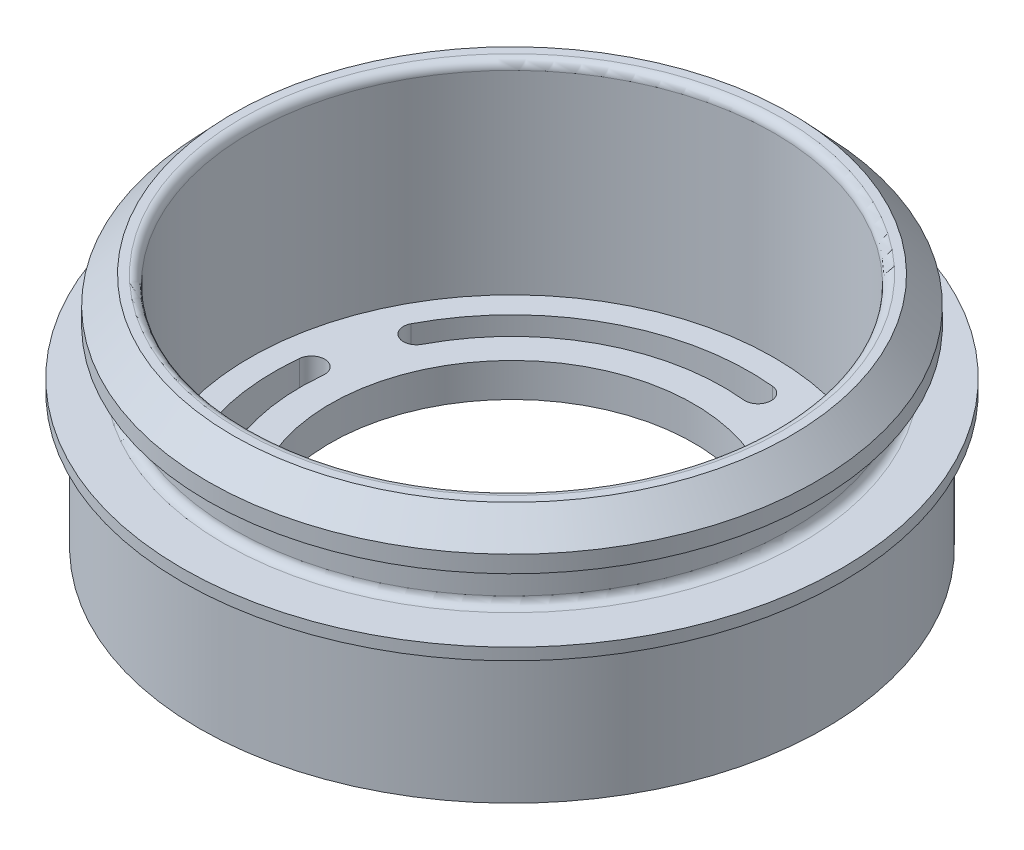
from build123d import *

# Parameters (mm, degrees)
CUT_EXTRUDE1_REACH = 4


with BuildPart() as part:
    # Sketch1 → Revolve1 (revolve)
    with BuildSketch(Plane.XY):
        with BuildLine():
            Line((-16.5, 9.4), (-18, 9.4))
            Line((-18, 9.4), (-18, 10.4))
            Line((-18, 10.4), (-16.5, 12))
            Line((-16.5, 12), (-16, 12))
            ThreePointArc((-16, 12), (-15.646446609, 11.853553391), (-15.5, 11.5))
            Line((-15.5, 11.5), (-15.5, 0))
            Line((-15.5, 0), (-10.75, 0))
            Line((-10.75, 0), (-10.75, -2))
            Line((-10.75, -2), (-18.5, -2))
            Line((-18.5, -2), (-18.5, 0))
            Line((-18.5, 0), (-18.5, 6))
            Line((-18.5, 6), (-19.5, 6))
            Line((-19.5, 6), (-19.5, 6.7))
            Line((-19.5, 6.7), (-17, 6.7))
            ThreePointArc((-17, 6.7), (-16.646446609, 6.846446609), (-16.5, 7.2))
            Line((-16.5, 7.2), (-16.5, 9.4))
        make_face()
    revolve(axis=Axis((0, 12.7, 0), (0, -1, 0)))

    # Sketch2 → Cut-Extrude1 (cut, up to next)
    with BuildSketch(Plane(origin=(0, 0, 0), x_dir=(1, 0, 0), z_dir=(0, 1, 0)), mode=Mode.PRIVATE) as cut_extrude1_sk1:
        with BuildLine():
            ThreePointArc((-13.984583698, 1.42392711), (-12.372295403, -6.672514973), (-6.49274382, -12.467575037))
            ThreePointArc((-6.49274382, -12.467575037), (-5.438109449, -12.135235565), (-5.770448921, -11.080601194))
            ThreePointArc((-5.770448921, -11.080601194), (-10.995921084, -5.930221166), (-12.42884798, 1.265520231))
            ThreePointArc((-12.42884798, 1.265520231), (-13.127512399, 2.12259153), (-13.984583698, 1.42392711))
        make_face()
    cut_extrude1_tool1 = extrude(cut_extrude1_sk1.sketch, amount=-CUT_EXTRUDE1_REACH, mode=Mode.PRIVATE) & part.part
    add(cut_extrude1_tool1.solids().sort_by_distance((-5.589512, 0, 12.05639))[0], mode=Mode.SUBTRACT)
    # Sketch2 → Cut-Extrude1 (cut, up to next)
    with BuildSketch(Plane(origin=(0, 0, 0), x_dir=(1, 0, 0), z_dir=(0, 1, 0)), mode=Mode.PRIVATE) as cut_extrude1_sk2:
        with BuildLine():
            ThreePointArc((1.42392711, 13.984583698), (-6.672514973, 12.372295403), (-12.467575037, 6.49274382))
            ThreePointArc((-12.467575037, 6.49274382), (-12.135235565, 5.438109449), (-11.080601194, 5.770448921))
            ThreePointArc((-11.080601194, 5.770448921), (-5.930221166, 10.995921084), (1.265520231, 12.42884798))
            ThreePointArc((1.265520231, 12.42884798), (2.12259153, 13.127512399), (1.42392711, 13.984583698))
        make_face()
    cut_extrude1_tool2 = extrude(cut_extrude1_sk2.sketch, amount=-CUT_EXTRUDE1_REACH, mode=Mode.PRIVATE) & part.part
    add(cut_extrude1_tool2.solids().sort_by_distance((-6.01125, 0, -11.146166))[0], mode=Mode.SUBTRACT)
    # Sketch2 → Cut-Extrude1 (cut, up to next)
    with BuildSketch(Plane(origin=(0, 0, 0), x_dir=(1, 0, 0), z_dir=(0, 1, 0)), mode=Mode.PRIVATE) as cut_extrude1_sk3:
        with BuildLine():
            ThreePointArc((13.984583698, -1.42392711), (12.372295403, 6.672514973), (6.49274382, 12.467575037))
            ThreePointArc((6.49274382, 12.467575037), (5.438109449, 12.135235565), (5.770448921, 11.080601194))
            ThreePointArc((5.770448921, 11.080601194), (10.995921084, 5.930221166), (12.42884798, -1.265520231))
            ThreePointArc((12.42884798, -1.265520231), (13.127512399, -2.12259153), (13.984583698, -1.42392711))
        make_face()
    cut_extrude1_tool3 = extrude(cut_extrude1_sk3.sketch, amount=-CUT_EXTRUDE1_REACH, mode=Mode.PRIVATE) & part.part
    add(cut_extrude1_tool3.solids().sort_by_distance((13.144804, 0, 1.952767))[0], mode=Mode.SUBTRACT)
    # Sketch2 → Cut-Extrude1 (cut, up to next)
    with BuildSketch(Plane(origin=(0, 0, 0), x_dir=(1, 0, 0), z_dir=(0, 1, 0)), mode=Mode.PRIVATE) as cut_extrude1_sk4:
        with BuildLine():
            ThreePointArc((-1.42392711, -13.984583698), (6.672514973, -12.372295403), (12.467575037, -6.49274382))
            ThreePointArc((12.467575037, -6.49274382), (12.135235565, -5.438109449), (11.080601194, -5.770448921))
            ThreePointArc((11.080601194, -5.770448921), (5.930221166, -10.995921084), (-1.265520231, -12.42884798))
            ThreePointArc((-1.265520231, -12.42884798), (-2.12259153, -13.127512399), (-1.42392711, -13.984583698))
        make_face()
    cut_extrude1_tool4 = extrude(cut_extrude1_sk4.sketch, amount=-CUT_EXTRUDE1_REACH, mode=Mode.PRIVATE) & part.part
    add(cut_extrude1_tool4.solids().sort_by_distance((6.01125, 0, 11.146166))[0], mode=Mode.SUBTRACT)


solid = part.part
